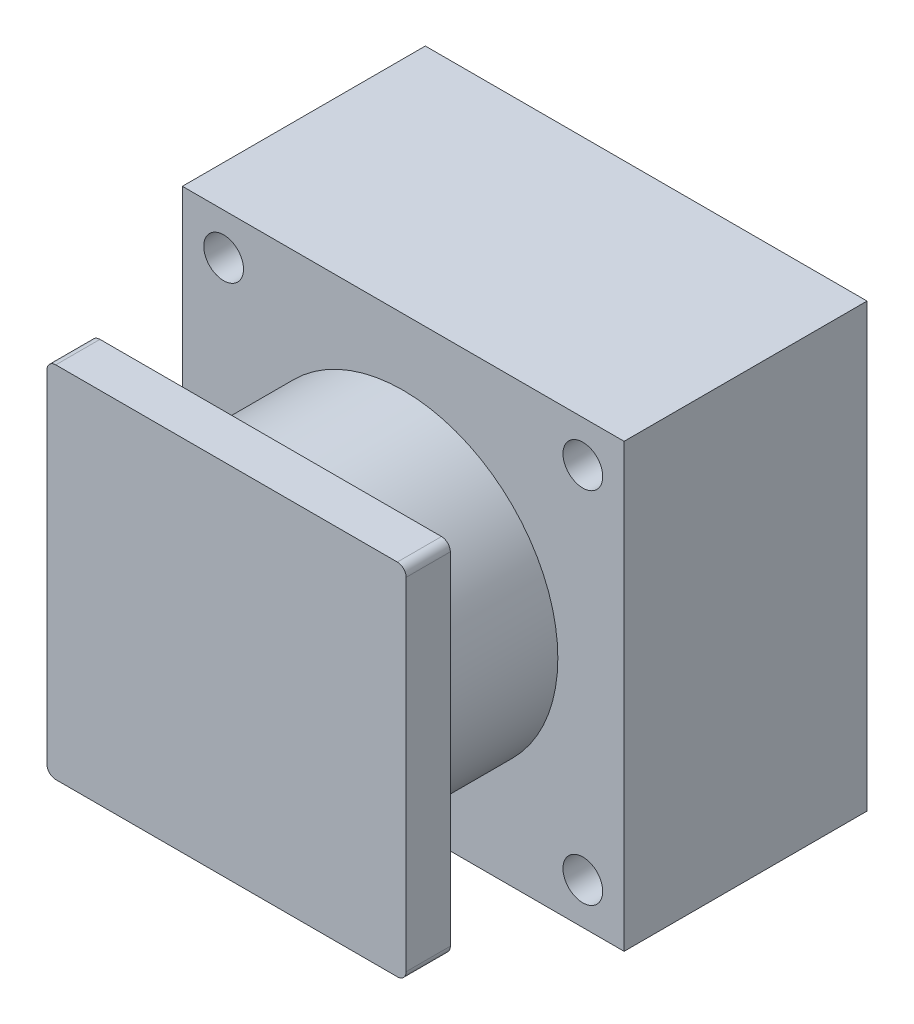
from build123d import *

# Parameters (mm, degrees)
SKETCH_1_W      = 100
SKETCH_1_H      = 100
SKETCH_1_R      = 4.5
EXTRUDE_1_DEPTH = 55
SKETCH_2_R      = 35
EXTRUDE_2_DEPTH = 30
SKETCH_3_W      = 81.317279836
SKETCH_3_H      = 81.317279836
EXTRUDE_3_DEPTH = 10
FILLET_1_R      = 2


with BuildPart() as part:
    # 草图1 → 凸台-拉伸1 (new body)
    with BuildSketch(Plane.XY):
        Rectangle(SKETCH_1_W, SKETCH_1_H)
        with Locations((-40.658639918, 40.658639918)):
            Circle(SKETCH_1_R, mode=Mode.SUBTRACT)
        with Locations((40.658639918, 40.658639918)):
            Circle(SKETCH_1_R, mode=Mode.SUBTRACT)
        with Locations((40.658639918, -40.658639918)):
            Circle(SKETCH_1_R, mode=Mode.SUBTRACT)
        with Locations((-40.658639918, -40.658639918)):
            Circle(SKETCH_1_R, mode=Mode.SUBTRACT)
    extrude(amount=EXTRUDE_1_DEPTH)

    # 草图2 → 凸台-拉伸2 (add)
    with BuildSketch(Plane.XY.offset(55)):
        Circle(SKETCH_2_R)
    extrude(amount=EXTRUDE_2_DEPTH)

    # 草图3 → 凸台-拉伸3 (add)
    with BuildSketch(Plane.XY.offset(85)):
        Rectangle(SKETCH_3_W, SKETCH_3_H)
    extrude(amount=EXTRUDE_3_DEPTH)

    # 圆角1
    fillet_1_edges = [part.edges().sort_by_distance(p)[0] for p in [
        (40.658639918, -40.658639918, 90),
        (40.658639918, 40.658639918, 90),
        (-40.658639918, 40.658639918, 90),
        (-40.658639918, -40.658639918, 90),
    ]]
    fillet(fillet_1_edges, radius=FILLET_1_R)


solid = part.part
